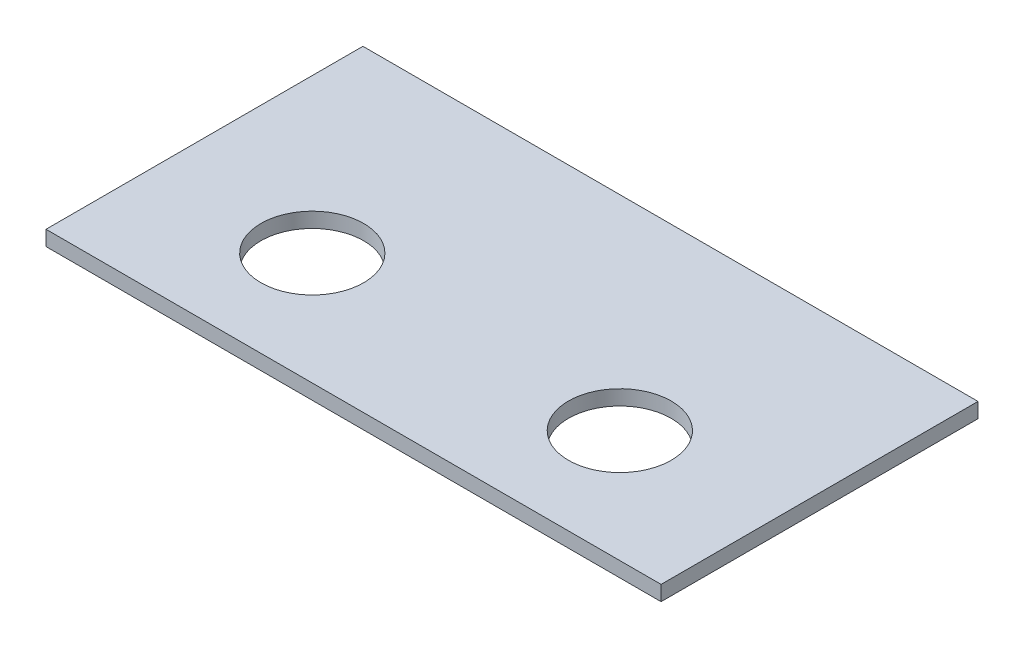
from build123d import *

# Parameters (mm, degrees)
SKETCH1_W           = 164
SKETCH1_H           = 84.5
SKETCH1_R           = 13.7
BOSS_EXTRUDE1_DEPTH = 4


with BuildPart() as part:
    # Sketch1 → Boss-Extrude1 (new body)
    with BuildSketch(Plane(origin=(0, 0, 0), x_dir=(1, 0, 0), z_dir=(0, 1, 0))):
        Rectangle(SKETCH1_W, SKETCH1_H)
        with Locations((-41, -12.25)):
            Circle(SKETCH1_R, mode=Mode.SUBTRACT)
        with Locations((41, -12.25)):
            Circle(SKETCH1_R, mode=Mode.SUBTRACT)
    extrude(amount=BOSS_EXTRUDE1_DEPTH)


solid = part.part
